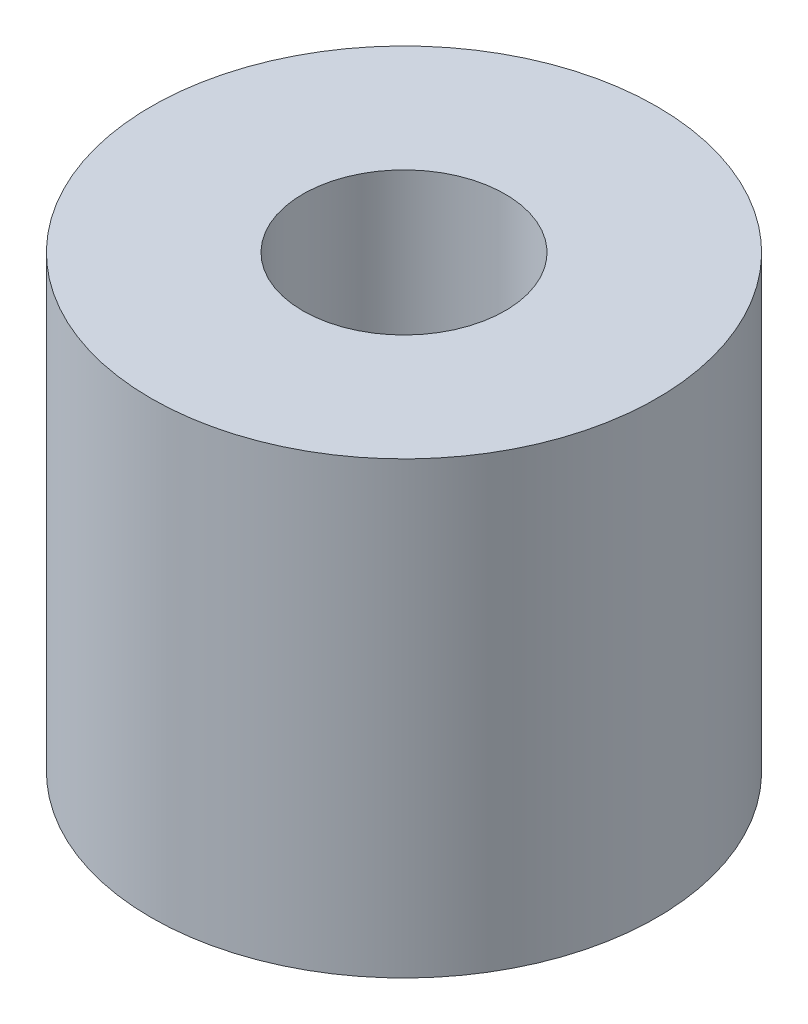
from build123d import *

# Parameters (mm, degrees)
CROQUIS1_R              = 4.5
CROQUIS1_R_2            = 1.8
SALIENTE_EXTRUIR1_DEPTH = 8


with BuildPart() as part:
    # Croquis1 → Saliente-Extruir1 (new body)
    with BuildSketch(Plane(origin=(0, 0, 0), x_dir=(1, 0, 0), z_dir=(0, 1, 0))):
        Circle(CROQUIS1_R)
        Circle(CROQUIS1_R_2, mode=Mode.SUBTRACT)
    extrude(amount=SALIENTE_EXTRUIR1_DEPTH)


solid = part.part
